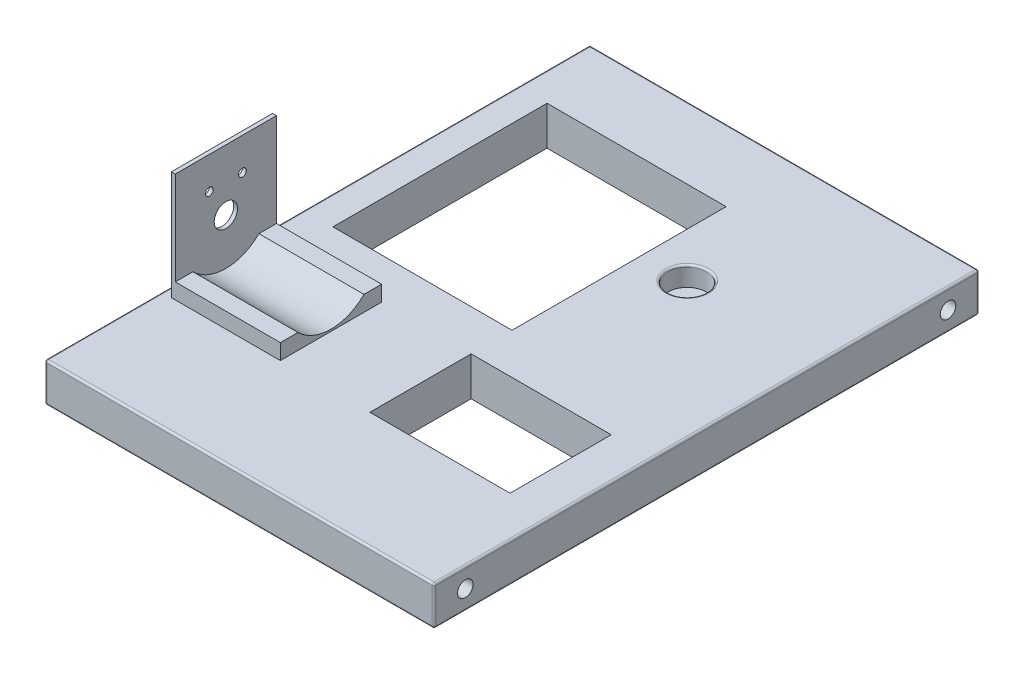
from build123d import *

# Parameters (mm, degrees)
SKETCH2_W               = 100
SKETCH2_H               = 140
BOSS_EXTRUDE1_DEPTH     = 10
SKETCH3_R               = 5
MOUNTHOLE_DEPTH         = 5
SKETCH4_R               = 2
CUT_EXTRUDE2_DEPTH      = 101
SKETCH5_R               = 2
CUT_EXTRUDE3_DEPTH      = 101
FILLET4_R               = 0.5
FILLET6_R               = 0.5
SKETCH7_W               = 28
SKETCH7_H               = 26
BOSS_EXTRUDE2_DEPTH     = 4
SKETCH21_W              = 46
SKETCH21_H              = 55
SKETCH21_W_2            = 36
SKETCH21_H_2            = 26
CUT_EXTRUDE10_DEPTH     = 11
SKETCH10_W              = 1
SKETCH10_H              = 26
BOSS_EXTRUDE3_DEPTH     = 24
SKETCH13_R              = 3
SKETCH13_R_2            = 1
CUT_EXTRUDE6_DEPTH      = 1
CUT_EXTRUDE9_DEPTH      = 70.5
CUT_EXTRUDE9_DEPTH_BACK = 27


with BuildPart() as part:
    # Sketch2 → Boss-Extrude1 (new body)
    with BuildSketch(Plane(origin=(0, 0, 0), x_dir=(1, 0, 0), z_dir=(0, 1, 0))):
        with Locations((50, 70)):
            Rectangle(SKETCH2_W, SKETCH2_H)
    extrude(amount=BOSS_EXTRUDE1_DEPTH)

    # Sketch3 → MountHole (cut)
    with BuildSketch(Plane(origin=(0, 10, 0), x_dir=(1, 0, 0), z_dir=(0, 1, 0))):
        with Locations((65, 100)):
            Circle(SKETCH3_R)
    extrude(amount=-MOUNTHOLE_DEPTH, mode=Mode.SUBTRACT)

    # Sketch4 → Cut-Extrude2 (cut, through all)
    with BuildSketch(Plane.ZY):
        with Locations((-8, 5)):
            Circle(SKETCH4_R)
    extrude(amount=-CUT_EXTRUDE2_DEPTH, mode=Mode.SUBTRACT)

    # Sketch5 → Cut-Extrude3 (cut, through all)
    with BuildSketch(Plane.ZY):
        with Locations((-132, 5)):
            Circle(SKETCH5_R)
    extrude(amount=-CUT_EXTRUDE3_DEPTH, mode=Mode.SUBTRACT)

    # Fillet4
    fillet4_edges = [part.edges().sort_by_distance(p)[0] for p in [
        (50, 10, -140),
        (0, 10, -70),
        (50, 10, 0),
        (0, 0, -70),
        (50, 0, -140),
        (100, 0, -70),
        (50, 0, 0),
        (0, 5, 0),
        (0, 5, -140),
        (100, 5, -140),
        (100, 5, 0),
        (100, 10, -70),
    ]]
    fillet(fillet4_edges, radius=FILLET4_R)

    # Fillet6
    fillet6_edges = [part.edges().sort_by_distance(p)[0] for p in [
        (60, 10, -100),
    ]]
    fillet(fillet6_edges, radius=FILLET6_R)

    # Sketch7 → Boss-Extrude2 (add)
    with BuildSketch(Plane(origin=(0, 10, 0), x_dir=(1, 0, 0), z_dir=(0, 1, 0))):
        with Locations((16.5, 43)):
            Rectangle(SKETCH7_W, SKETCH7_H)
    extrude(amount=BOSS_EXTRUDE2_DEPTH)

    # Sketch21 → Cut-Extrude10 (cut, through all)
    with BuildSketch(Plane(origin=(0, 10, 0), x_dir=(1, 0, 0), z_dir=(0, 1, 0))):
        with Locations((30.5, 94)):
            Rectangle(SKETCH21_W, SKETCH21_H)
        with Locations((71.5, 43)):
            Rectangle(SKETCH21_W_2, SKETCH21_H_2)
    extrude(amount=-CUT_EXTRUDE10_DEPTH, mode=Mode.SUBTRACT)

    # Sketch10 → Boss-Extrude3 (add)
    with BuildSketch(Plane(origin=(0, 14, 0), x_dir=(1, 0, 0), z_dir=(0, 1, 0))):
        with Locations((3, 43)):
            Rectangle(SKETCH10_W, SKETCH10_H)
    extrude(amount=BOSS_EXTRUDE3_DEPTH)

    # Sketch13 → Cut-Extrude6 (cut)
    with BuildSketch(Plane.ZY.offset(-2.5)):
        with Locations((-43, 22.354)):
            Circle(SKETCH13_R)
        with Locations((-38.75, 29.715215932)):
            Circle(SKETCH13_R_2)
        with Locations((-47.25, 29.715215932)):
            Circle(SKETCH13_R_2)
    extrude(amount=-CUT_EXTRUDE6_DEPTH, mode=Mode.SUBTRACT)

    # Sketch20 → Cut-Extrude9 (cut, two sides)
    with BuildSketch(Plane(origin=(30.5, 0, 0), x_dir=(0, 0, -1), z_dir=(1, 0, 0))) as cut_extrude9_sk:
        with BuildLine():
            Line((-205.175487121, 14), (30, 14))
            Line((30, 14), (34.519834012, 14))
            ThreePointArc((34.519834012, 14), (43, 10.490393679), (51.480165988, 14))
            Line((51.480165988, 14), (56, 14))
            Line((56, 14), (291.175487121, 14))
            Line((291.175487121, 14), (291.175487121, 484.350974241))
            Line((291.175487121, 484.350974241), (-205.175487121, 484.350974241))
            Line((-205.175487121, 484.350974241), (-205.175487121, 14))
        make_face()
    extrude(amount=CUT_EXTRUDE9_DEPTH, mode=Mode.SUBTRACT)
    extrude(cut_extrude9_sk.sketch, amount=-CUT_EXTRUDE9_DEPTH_BACK, mode=Mode.SUBTRACT)


solid = part.part
